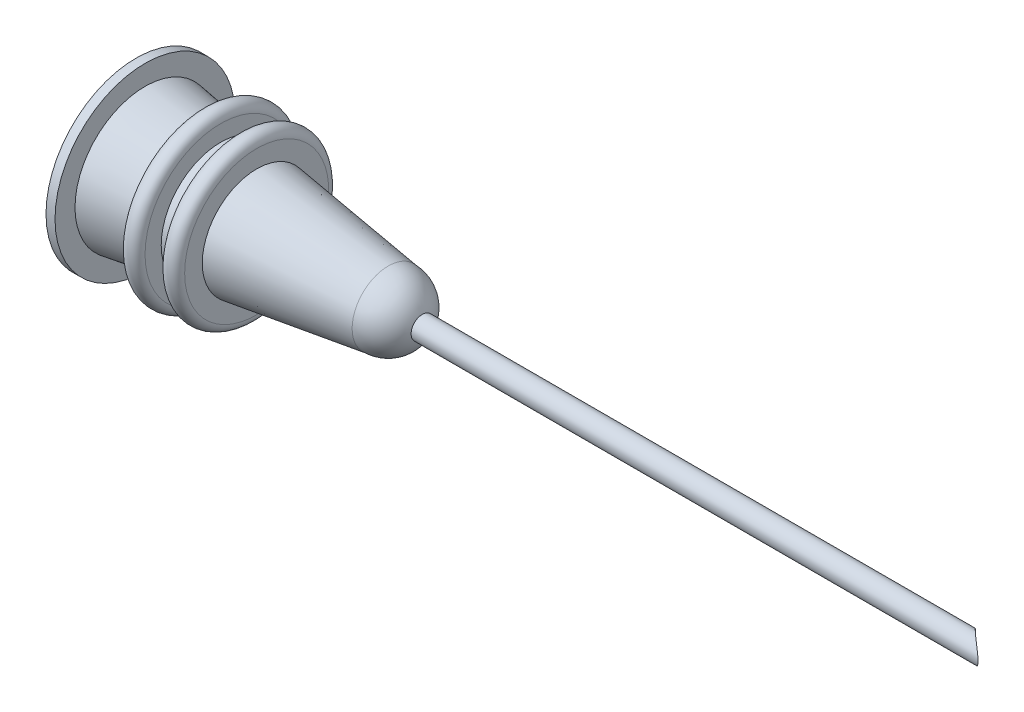
from build123d import *

# Parameters (mm, degrees)
DOME1_FACE_RADIUS       = 2
DOME1_HEIGHT            = 2
SKETCH5_R               = 0.5
CUT_EXTRUDE1_DEPTH      = 4
SKETCH6_R               = 0.625
SKETCH6_R_2             = 0.5
EXTRUDE_THIN1_DEPTH     = 40
SKETCH7_R               = 9.506624516
CUT_EXTRUDE2_DEPTH      = 6
CUT_EXTRUDE2_DEPTH_BACK = 6


with BuildPart() as part:
    # Sketch2 → Revolve1 (revolve)
    with BuildSketch(Plane.XY):
        with BuildLine():
            Line((0, 0), (-1, 0))
            Line((-1, 0), (-1, 1.382676537))
            Line((-1, 1.382676537), (-14, 3.202544081))
            Line((-14, 3.202544081), (-14, 3.240195922))
            Line((-14, 3.240195922), (-14, 5))
            Line((-14, 5), (-13.5, 5))
            Line((-13.5, 5), (-13.5, 3.889862449))
            Line((-13.5, 3.889862449), (-10.3, 3.441895054))
            Line((-10.3, 3.441895054), (-10.3, 4.2))
            ThreePointArc((-10.3, 4.2), (-9.8, 4.7), (-9.3, 4.2))
            Line((-9.3, 4.2), (-9.3, 3.301905243))
            Line((-9.3, 3.301905243), (-8.3, 3.161915432))
            Line((-8.3, 3.161915432), (-8.3, 4))
            ThreePointArc((-8.3, 4), (-7.8, 4.5), (-7.3, 4))
            Line((-7.3, 4), (-7.3, 3.021925621))
            Line((-7.3, 3.021925621), (0, 2))
            Line((0, 2), (0, 0))
        make_face()
    revolve(axis=Axis((-26.179667308, 0, 0), (1, 0, 0)))

    # Dome1: a dome of height H over a round flat face of radius A is a cap of a sphere of radius (A * A + H * H) / (2 * H)
    dome1_r = (DOME1_FACE_RADIUS * DOME1_FACE_RADIUS + DOME1_HEIGHT * DOME1_HEIGHT) / (2 * DOME1_HEIGHT)
    dome1_base = Plane((0, 0, 0), z_dir=(1, 0, 0))
    with Locations(dome1_base.offset(DOME1_HEIGHT - dome1_r)):
        dome1_ball = Sphere(dome1_r, mode=Mode.PRIVATE)
    add(split(dome1_ball, bisect_by=dome1_base, keep=Keep.TOP, mode=Mode.PRIVATE))

    # Sketch5 → Cut-Extrude1 (cut, through all)
    with BuildSketch(Plane.ZY.offset(1)):
        Circle(SKETCH5_R)
    extrude(amount=-CUT_EXTRUDE1_DEPTH, mode=Mode.SUBTRACT)

    # Sketch6 → Extrude-Thin1 (add)
    with BuildSketch(Plane.ZY.offset(1)):
        Circle(SKETCH6_R)
        Circle(SKETCH6_R_2, mode=Mode.SUBTRACT)
    extrude(amount=-EXTRUDE_THIN1_DEPTH)

    # Sketch7 → Cut-Extrude2 (cut, two sides)
    with BuildSketch(Plane(origin=(0, 0, 0), x_dir=(1, 0, 0), z_dir=(0, 1, 0))) as cut_extrude2_sk:
        with Locations((39, 7.04259074)):
            Circle(SKETCH7_R)
    extrude(amount=CUT_EXTRUDE2_DEPTH, mode=Mode.SUBTRACT)
    extrude(cut_extrude2_sk.sketch, amount=-CUT_EXTRUDE2_DEPTH_BACK, mode=Mode.SUBTRACT)


solid = part.part
